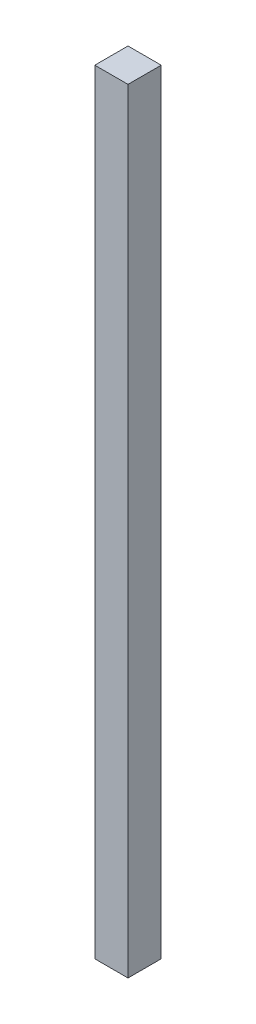
from build123d import *

# Parameters (mm, degrees)
ESQUISSE1_W        = 10
ESQUISSE1_H        = 233
BOSS_EXTRU_1_DEPTH = 10


with BuildPart() as part:
    # Esquisse1 → Boss.-Extru.1 (new body)
    with BuildSketch(Plane.XY):
        with Locations((-46.666666667, -46.857142857)):
            Rectangle(ESQUISSE1_W, ESQUISSE1_H)
    extrude(amount=BOSS_EXTRU_1_DEPTH)


solid = part.part
